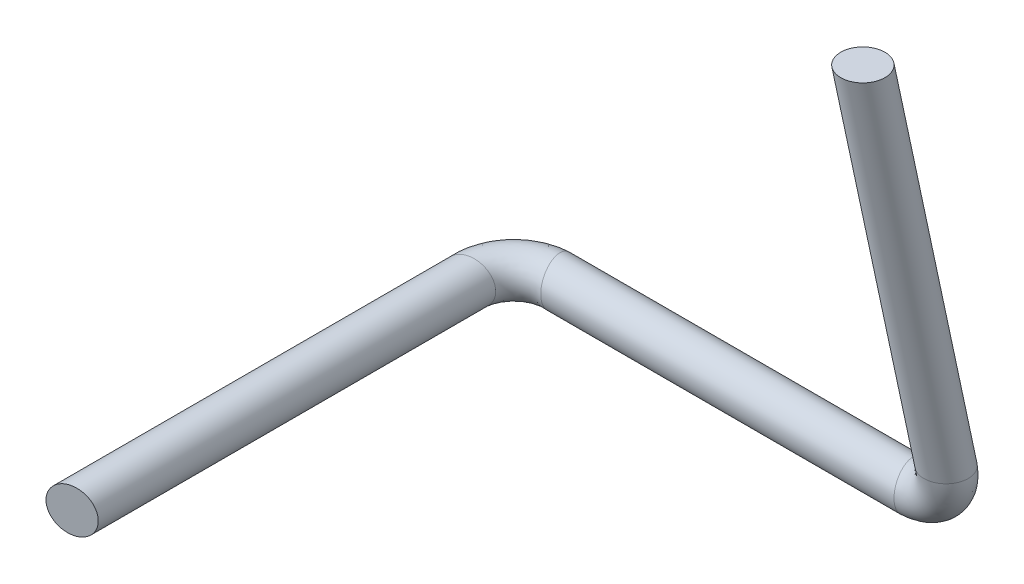
from build123d import *

# Parameters (mm, degrees)
ESBO_O2_R = 5


with BuildPart() as part:
    # Varredura1: sweep along a curve in space
    with BuildLine() as varredura1_path:
        Line((0, 0, 0), (0.038142125, -88.008826842, -18.806432963))
        ThreePointArc((0.038142125, -88.008826842, -18.806432963), (-2.889290888, -94.926458775, -20.284648113), (-9.961856976, -97.792191514, -20.897020901))
        Line((-9.961856976, -97.792191514, -20.897020901), (-89.957617864, -97.792191514, -20.897020901))
        ThreePointArc((-89.957617864, -97.792191514, -20.897020901), (-97.028685676, -97.792191514, -17.968088713), (-99.957617864, -97.792191514, -10.897020901))
        Line((-99.957617864, -97.792191514, -10.897020901), (-99.957617864, -97.792191514, 79.102979099))
    # Esboço2 → Varredura1 (sweep)
    with BuildSketch(Plane(origin=(0, 0, 0), x_dir=(1, 0, 0), z_dir=(0, 1, 0))):
        Circle(ESBO_O2_R)
    sweep(path=varredura1_path.line)


solid = part.part
